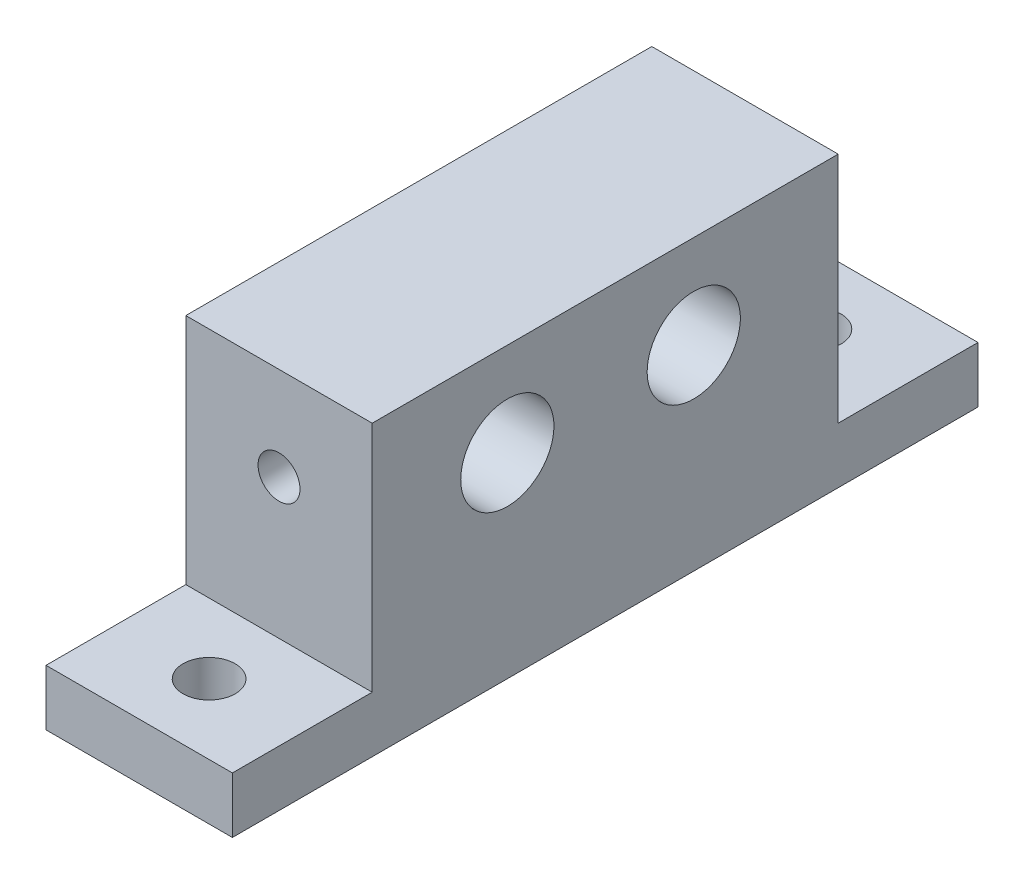
from build123d import *

# Parameters (mm, degrees)
SKETCH_1_W          = 10
SKETCH_1_H          = 25
EXTRUDE_1_DEPTH     = 10
SKETCH_2_R          = 2.5
CUT_EXTRUDE_1_DEPTH = 10
CUT_EXTRUDE_2_REACH = 27
SKETCH_3_R          = 1.125
CUT_EXTRUDE_3_REACH = 27
SKETCH_4_R          = 1.125
SKETCH_5_W          = 10
SKETCH_5_H          = 25
EXTRUDE_2_DEPTH     = 2.5
SKETCH_6_W          = 10
SKETCH_6_H          = 40
EXTRUDE_3_DEPTH     = 3
SKETCH_7_R          = 1.4
CUT_EXTRUDE_4_DEPTH = 3


with BuildPart() as part:
    # 스케치1 → 보스-돌출1 (new body)
    with BuildSketch(Plane(origin=(0, 0, 0), x_dir=(1, 0, 0), z_dir=(0, 1, 0))):
        with Locations((-4.093959732, 10.604026846)):
            Rectangle(SKETCH_1_W, SKETCH_1_H)
    extrude(amount=EXTRUDE_1_DEPTH)

    # 스케치2 → 컷-돌출1 (cut)
    with BuildSketch(Plane.ZY.offset(9.093959732)):
        with Locations((-5.354026846, 5)):
            Circle(SKETCH_2_R)
        with Locations((-15.354026846, 5)):
            Circle(SKETCH_2_R)
    extrude(amount=-CUT_EXTRUDE_1_DEPTH, mode=Mode.SUBTRACT)

    # 스케치3 → 컷-돌출2 (cut, up to next)
    with BuildSketch(Plane.XY.offset(1.895973154), mode=Mode.PRIVATE) as cut_extrude_2_sk1:
        with Locations((-4.093959732, 5)):
            Circle(SKETCH_3_R)
    cut_extrude_2_tool1 = extrude(cut_extrude_2_sk1.sketch, amount=-CUT_EXTRUDE_2_REACH, mode=Mode.PRIVATE) & part.part
    add(cut_extrude_2_tool1.solids().sort_by_distance((-4.09396, 5, 1.895973))[0], mode=Mode.SUBTRACT)

    # 스케치4 → 컷-돌출3 (cut, up to next)
    with BuildSketch(Plane(origin=(0, 0, -23.104026846), x_dir=(-1, 0, 0), z_dir=(0, 0, -1)), mode=Mode.PRIVATE) as cut_extrude_3_sk1:
        with Locations((4.093959732, 5)):
            Circle(SKETCH_4_R)
    cut_extrude_3_tool1 = extrude(cut_extrude_3_sk1.sketch, amount=-CUT_EXTRUDE_3_REACH, mode=Mode.PRIVATE) & part.part
    add(cut_extrude_3_tool1.solids().sort_by_distance((-4.09396, 5, -23.104027))[0], mode=Mode.SUBTRACT)

    # 스케치5 → 보스-돌출2 (add)
    with BuildSketch(Plane.XZ):
        with Locations((-4.093959732, -10.604026846)):
            Rectangle(SKETCH_5_W, SKETCH_5_H)
    extrude(amount=EXTRUDE_2_DEPTH)

    # 스케치6 → 보스-돌출3 (add)
    with BuildSketch(Plane.XZ.offset(2.5)):
        with Locations((-4.093959732, -10.604026846)):
            Rectangle(SKETCH_6_W, SKETCH_6_H)
    extrude(amount=EXTRUDE_3_DEPTH)

    # 스케치7 → 컷-돌출4 (cut)
    with BuildSketch(Plane(origin=(0, -2.5, 0), x_dir=(1, 0, 0), z_dir=(0, 1, 0))):
        with Locations((-4.093959732, -5.645973154)):
            Circle(SKETCH_7_R)
        with Locations((-4.093959732, 26.854026846)):
            Circle(SKETCH_7_R)
    extrude(amount=-CUT_EXTRUDE_4_DEPTH, mode=Mode.SUBTRACT)


solid = part.part
